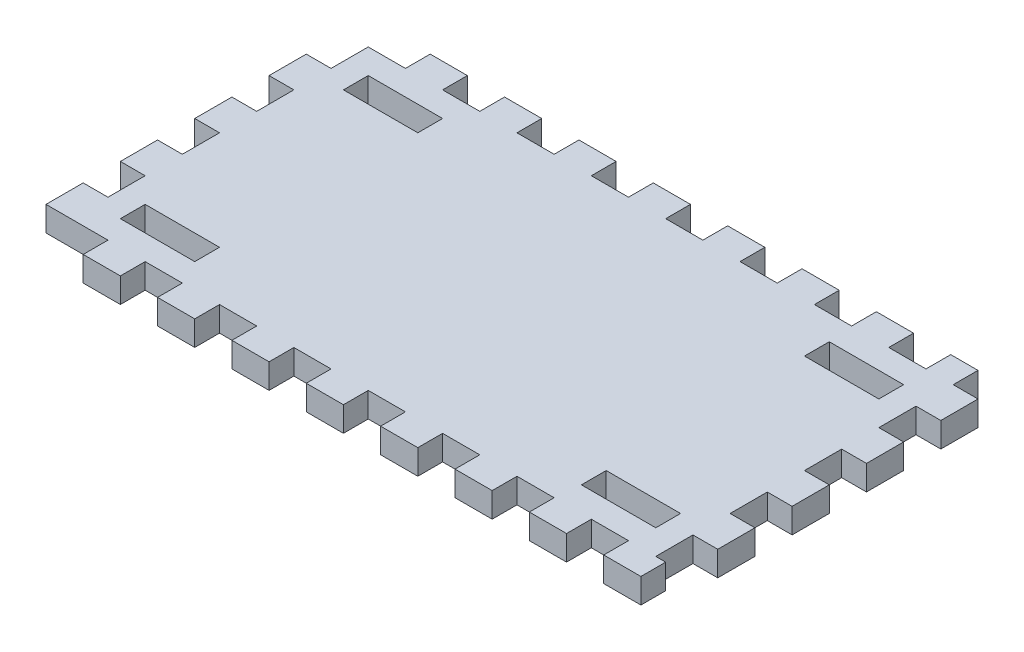
from build123d import *

# Parameters (mm, degrees)
SKETCH1_W           = 149.86
SKETCH1_H           = 76.2
SKETCH1_W_2         = 19.05
SKETCH1_H_2         = 6.35
BOSS_EXTRUDE1_DEPTH = 6.35
SKETCH2_W           = 6.35
SKETCH2_H           = 9.525
SKETCH2_W_2         = 9.525
SKETCH2_H_2         = 6.35
SKETCH2_W_3         = 6.985
BOSS_EXTRUDE2_DEPTH = 6.35


with BuildPart() as part:
    # Sketch1 → Boss-Extrude1 (new body)
    with BuildSketch(Plane(origin=(0, 0, 0), x_dir=(1, 0, 0), z_dir=(0, 1, 0))):
        with Locations((74.93, -38.1)):
            Rectangle(SKETCH1_W, SKETCH1_H)
        with Locations((15.875, -66.675)):
            Rectangle(SKETCH1_W_2, SKETCH1_H_2, mode=Mode.SUBTRACT)
        with Locations((15.875, -9.525)):
            Rectangle(SKETCH1_W_2, SKETCH1_H_2, mode=Mode.SUBTRACT)
        with Locations((133.985, -66.675)):
            Rectangle(SKETCH1_W_2, SKETCH1_H_2, mode=Mode.SUBTRACT)
        with Locations((133.985, -9.525)):
            Rectangle(SKETCH1_W_2, SKETCH1_H_2, mode=Mode.SUBTRACT)
    extrude(amount=BOSS_EXTRUDE1_DEPTH)

    # Sketch2 → Boss-Extrude2 (add)
    with BuildSketch(Plane.XZ):
        with Locations((-3.175, 52.3875)):
            Rectangle(SKETCH2_W, SKETCH2_H)
        with Locations((-3.175, 33.3375)):
            Rectangle(SKETCH2_W, SKETCH2_H)
        with Locations((14.2875, -3.175)):
            Rectangle(SKETCH2_W_2, SKETCH2_H_2)
        with Locations((52.3875, -3.175)):
            Rectangle(SKETCH2_W_2, SKETCH2_H_2)
        with Locations((71.4375, -3.175)):
            Rectangle(SKETCH2_W_2, SKETCH2_H_2)
        with Locations((90.4875, -3.175)):
            Rectangle(SKETCH2_W_2, SKETCH2_H_2)
        with Locations((128.5875, -3.175)):
            Rectangle(SKETCH2_W_2, SKETCH2_H_2)
        with Locations((146.3675, -3.175)):
            Rectangle(SKETCH2_W_3, SKETCH2_H_2)
        with Locations((153.035, 42.8625)):
            Rectangle(SKETCH2_W, SKETCH2_H)
        Polygon((142.875, 82.55), (142.875, 76.2), (149.86, 76.2), (152.4, 76.2), (152.4, 82.55), align=None)
        with Locations((109.5375, 79.375)):
            Rectangle(SKETCH2_W_2, SKETCH2_H_2)
        with Locations((90.4875, 79.375)):
            Rectangle(SKETCH2_W_2, SKETCH2_H_2)
        with Locations((33.3375, 79.375)):
            Rectangle(SKETCH2_W_2, SKETCH2_H_2)
        with Locations((14.2875, 79.375)):
            Rectangle(SKETCH2_W_2, SKETCH2_H_2)
        with Locations((128.5875, 79.375)):
            Rectangle(SKETCH2_W_2, SKETCH2_H_2)
        with Locations((-3.175, 71.4375)):
            Rectangle(SKETCH2_W, SKETCH2_H)
        with Locations((-3.175, 14.2875)):
            Rectangle(SKETCH2_W, SKETCH2_H)
        with Locations((33.3375, -3.175)):
            Rectangle(SKETCH2_W_2, SKETCH2_H_2)
        with Locations((109.5375, -3.175)):
            Rectangle(SKETCH2_W_2, SKETCH2_H_2)
        with Locations((153.035, 4.7625)):
            Rectangle(SKETCH2_W, SKETCH2_H)
        with Locations((153.035, 23.8125)):
            Rectangle(SKETCH2_W, SKETCH2_H)
        with Locations((153.035, 61.9125)):
            Rectangle(SKETCH2_W, SKETCH2_H)
        with Locations((71.4375, 79.375)):
            Rectangle(SKETCH2_W_2, SKETCH2_H_2)
        with Locations((52.3875, 79.375)):
            Rectangle(SKETCH2_W_2, SKETCH2_H_2)
    extrude(amount=-BOSS_EXTRUDE2_DEPTH)


solid = part.part
